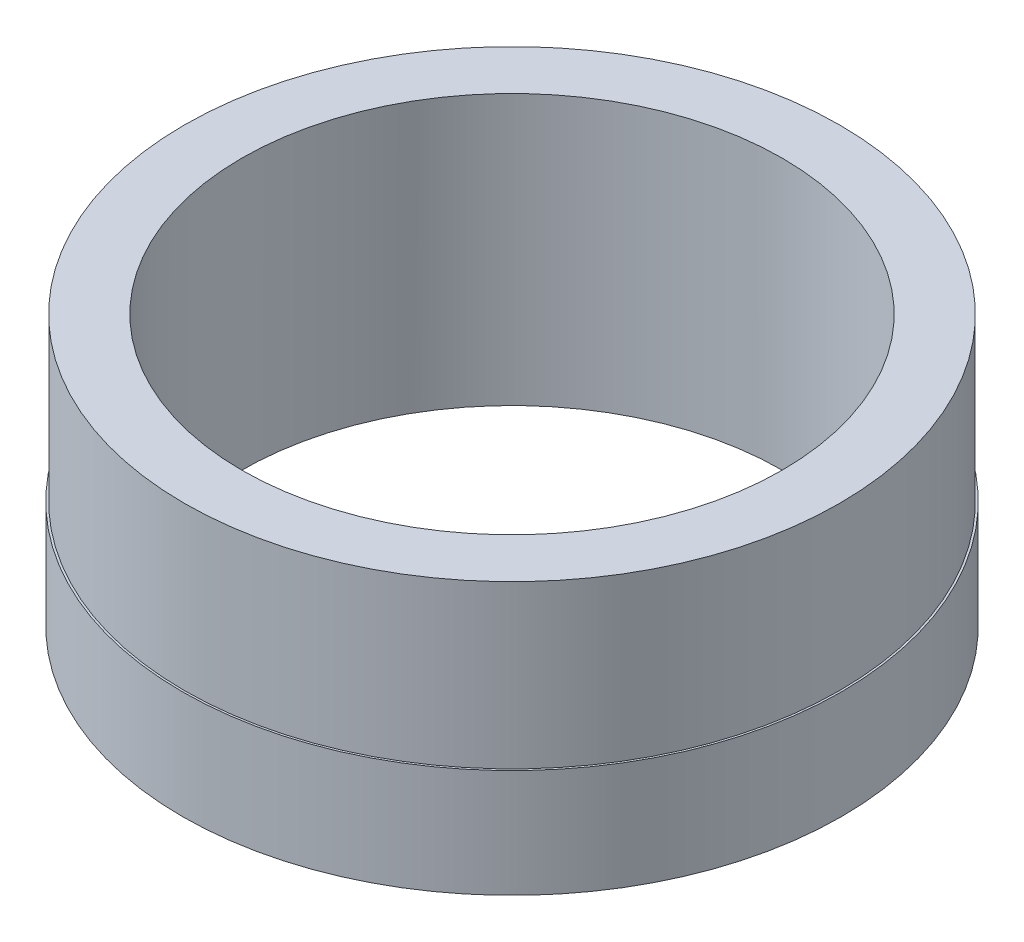
from build123d import *

# Parameters (mm, degrees)
SKETCH_1_R          = 24.4
EXTRUDE_1_DEPTH     = 8
SKETCH_2_R          = 24.25
EXTRUDE_2_DEPTH     = 12
SKETCH_3_R          = 20
CUT_EXTRUDE_1_DEPTH = 29


with BuildPart() as part:
    # Эскиз1 → Бобышка-Вытянуть1 (new body)
    with BuildSketch(Plane(origin=(0, 0, 0), x_dir=(1, 0, 0), z_dir=(0, 1, 0))):
        Circle(SKETCH_1_R)
    extrude(amount=EXTRUDE_1_DEPTH)

    # Эскиз2 → Бобышка-Вытянуть2 (add)
    with BuildSketch(Plane(origin=(0, 8, 0), x_dir=(1, 0, 0), z_dir=(0, 1, 0))):
        Circle(SKETCH_2_R)
    extrude(amount=EXTRUDE_2_DEPTH)

    # Эскиз3 → Вырез-Вытянуть1 (cut)
    with BuildSketch(Plane.XZ):
        Circle(SKETCH_3_R)
    extrude(amount=-CUT_EXTRUDE_1_DEPTH, mode=Mode.SUBTRACT)


solid = part.part
